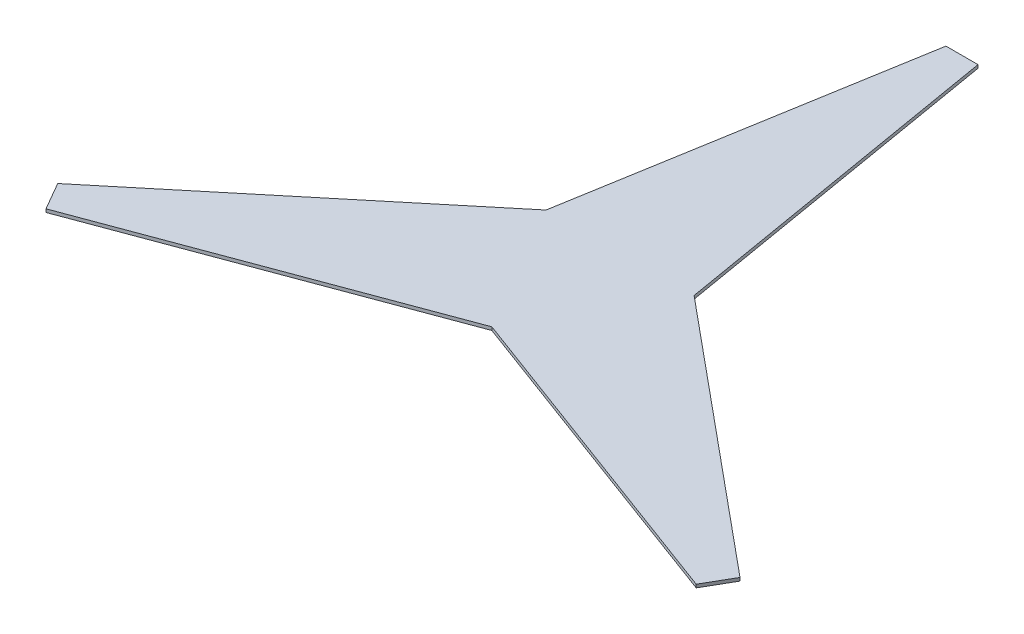
from build123d import *

# Parameters (mm, degrees)
SALIENTE_EXTRUIR2_DEPTH = 10


with BuildPart() as part:
    # Croquis1 → Saliente-Extruir2 (new body)
    with BuildSketch(Plane(origin=(0, 0, 0), x_dir=(1, 0, 0), z_dir=(0, 1, 0))):
        Polygon((1064.230484541, -556.698729811), (230.951615741, 133.339977518), (50, 1200), (-50, 1200), (-230.951615741, 133.339977518), (-1064.230484541, -556.698729811), (-1014.230484541, -643.301270189), (0, -266.679955035), (1014.230484541, -643.301270189), align=None)
    extrude(amount=SALIENTE_EXTRUIR2_DEPTH)


solid = part.part
